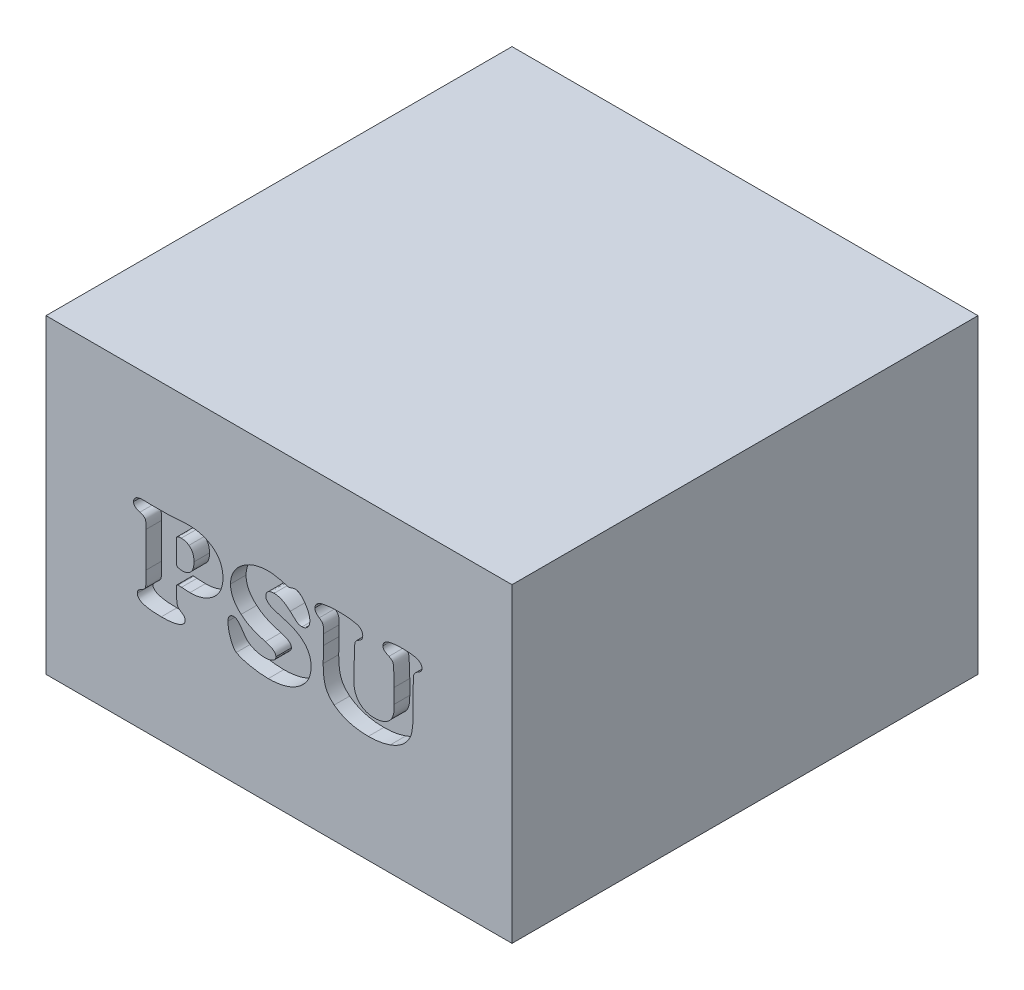
from build123d import *

# Parameters (mm, degrees)
SKETCH1_W           = 150
SKETCH1_H           = 100
BOSS_EXTRUDE1_DEPTH = 150
CUT_EXTRUDE1_DEPTH  = 5


with BuildPart() as part:
    # Sketch1 → Boss-Extrude1 (new body)
    with BuildSketch(Plane.XY):
        Rectangle(SKETCH1_W, SKETCH1_H)
    extrude(amount=BOSS_EXTRUDE1_DEPTH)

    # Sketch2 → Cut-Extrude1 (cut)
    with BuildSketch(Plane.XY.offset(150)):
        with BuildLine():
            Line((-42.77027027, -4.80785473), (-42.77027027, 6.549831081))
            add(Edge.make_bspline(
                [(-42.77027027, 6.549831081), (-42.772098153, 6.725076622), (-42.775578205, 7.058721365), (-42.784930055, 7.534192395), (-42.813709706, 7.958319786), (-42.838004289, 8.333692021), (-42.894502709, 8.655443685), (-42.940993941, 8.931795845), (-43.000430271, 9.158369889), (-43.105235457, 9.400980283), (-43.320470361, 9.658958937), (-43.69595349, 9.913608546), (-44.199479498, 10.134999027), (-44.586565073, 10.245828929), (-44.797297297, 10.306165541)],
                knots=[0, 0, 0, 0, 1.304378784, 2.483367747, 3.538098266, 4.46856333, 5.279790937, 5.967099256, 6.554232707, 7.018535437, 7.924119045, 9.005552902, 10.36980105, 12, 12, 12, 12], degree=3))
            add(Edge.make_bspline(
                [(-44.797297297, 10.306165541), (-44.956796659, 10.353603075), (-45.259647968, 10.443675659), (-45.673839465, 10.622008889), (-46.029622976, 10.82234981), (-46.315821176, 11.058757957), (-46.545599556, 11.314691154), (-46.708874532, 11.601120539), (-46.806432649, 11.915211484), (-46.818322314, 12.134042341), (-46.824324324, 12.244510135)],
                knots=[0, 0, 0, 0, 1.316136863, 2.499030521, 3.562546638, 4.536248738, 5.424589138, 6.270403347, 7.126883983, 8, 8, 8, 8], degree=3))
            add(Edge.make_bspline(
                [(-46.824324324, 12.244510135), (-46.815263653, 12.397865405), (-46.79765399, 12.695915569), (-46.640540067, 13.11398885), (-46.375274516, 13.468839318), (-46.006840918, 13.757650898), (-45.544234503, 13.982228937), (-44.992489559, 14.145372005), (-44.352684354, 14.236682599), (-43.898103778, 14.247041637), (-43.657094595, 14.252533784)],
                knots=[0, 0, 0, 0, 0.870962006, 1.6927385, 2.500678786, 3.364391329, 4.332200649, 5.412372546, 6.628093649, 8, 8, 8, 8], degree=3))
            add(Edge.make_bspline(
                [(-43.657094595, 14.252533784), (-43.540968475, 14.250125309), (-43.243281066, 14.243951223), (-42.702475979, 14.243371633), (-41.972284529, 14.208974172), (-41.423178303, 14.196272251), (-41.116976351, 14.189189189)],
                knots=[0, 0, 0, 0, 0.548528131, 1.406142903, 2.553569298, 4, 4, 4, 4], degree=3))
            Line((-41.116976351, 14.189189189), (-39.831081081, 14.189189189))
            add(Edge.make_bspline(
                [(-39.831081081, 14.189189189), (-39.550256398, 14.192078043), (-39.020286032, 14.197529867), (-38.270673852, 14.193493368), (-37.614010856, 14.20081389), (-37.048167068, 14.210427578), (-36.575136487, 14.205767957), (-36.192966792, 14.213891769), (-35.90371225, 14.220070219), (-35.67337697, 14.225445965), (-35.441509504, 14.243880882), (-35.141175479, 14.251183716), (-34.742474879, 14.28141317), (-34.246147127, 14.310755949), (-33.652891543, 14.350001171), (-32.962417266, 14.394020887), (-32.172711066, 14.444548921), (-31.613174393, 14.480555301), (-31.317567568, 14.499577703)],
                knots=[0, 0, 0, 0, 1.581728074, 2.985026098, 4.22188831, 5.280374816, 6.172301526, 6.88594199, 7.433119622, 7.801974425, 8.183272369, 8.742718937, 9.493445995, 10.434821951, 11.543110428, 12.842047549, 14.331633399, 16, 16, 16, 16], degree=3))
            add(Edge.make_bspline(
                [(-31.317567568, 14.499577703), (-30.922869794, 14.526452896), (-30.169875905, 14.577724673), (-29.415242016, 14.589155486), (-29.056165541, 14.594594595)],
                knots=[0, 0, 0, 0, 1.048342567, 2, 2, 2, 2], degree=3))
            add(Edge.make_bspline(
                [(-29.056165541, 14.594594595), (-28.766815243, 14.588665069), (-28.197995098, 14.577008492), (-27.355516892, 14.516438752), (-26.538401285, 14.397424015), (-25.741037708, 14.251795905), (-24.971549978, 14.046393679), (-24.229188453, 13.795642433), (-23.502800478, 13.517183891), (-23.040904426, 13.285144056), (-22.810388514, 13.169341216)],
                knots=[0, 0, 0, 0, 1.073806442, 2.11094559, 3.131408765, 4.136324753, 5.116910564, 6.083150564, 7.043368532, 8, 8, 8, 8], degree=3))
            add(Edge.make_bspline(
                [(-22.810388514, 13.169341216), (-22.432447417, 12.959633997), (-21.696163971, 12.551094265), (-20.721601009, 11.786626748), (-19.88693541, 10.941345718), (-19.204518995, 9.998496719), (-18.682947262, 8.959506883), (-18.307220781, 7.833788986), (-18.082683203, 6.617834481), (-18.054848456, 5.777989792), (-18.040540541, 5.346283784)],
                knots=[0, 0, 0, 0, 1.068766056, 2.082109524, 3.054420253, 4.001901685, 4.951155553, 5.921609222, 6.931643197, 8, 8, 8, 8], degree=3))
            add(Edge.make_bspline(
                [(-18.040540541, 5.346283784), (-18.049754855, 4.993085393), (-18.067776802, 4.302277277), (-18.22429312, 3.293333749), (-18.476859743, 2.336827925), (-18.832478108, 1.432473224), (-19.29138141, 0.583260635), (-19.856154976, -0.206920047), (-20.516675217, -0.949396449), (-21.02506347, -1.386506222), (-21.283783784, -1.608952703)],
                knots=[0, 0, 0, 0, 1.065407665, 2.0837928, 3.073052064, 4.045753518, 5.009500808, 5.978437762, 6.971220887, 8, 8, 8, 8], degree=3))
            add(Edge.make_bspline(
                [(-21.283783784, -1.608952703), (-21.54253317, -1.803399498), (-22.058179146, -2.190900736), (-22.88388564, -2.691639244), (-23.75154583, -3.113017398), (-24.66079063, -3.452179365), (-25.605823372, -3.729229279), (-26.594556314, -3.915858733), (-27.621725019, -4.033165494), (-28.321042624, -4.047019925), (-28.676097973, -4.054054054)],
                knots=[0, 0, 0, 0, 0.97791957, 1.948836665, 2.913671988, 3.889276902, 4.879079586, 5.886727176, 6.927055728, 8, 8, 8, 8], degree=3))
            add(Edge.make_bspline(
                [(-28.676097973, -4.054054054), (-28.870405211, -4.05370254), (-29.280385971, -4.05296086), (-29.924193976, -4.014821322), (-30.631912283, -3.973499523), (-31.123399671, -3.930756494), (-31.380912162, -3.908361486)],
                knots=[0, 0, 0, 0, 0.860351216, 1.815307805, 2.855340867, 4, 4, 4, 4], degree=3))
            add(Edge.make_bspline(
                [(-31.380912162, -3.908361486), (-31.509802045, -3.901304), (-31.740246919, -3.888685775), (-32.043387073, -3.85444424), (-32.26782293, -3.853470886), (-32.390216001, -3.847417965), (-32.438766892, -3.845016892)],
                knots=[0, 0, 0, 0, 1.461298414, 2.612685507, 3.449679997, 4, 4, 4, 4], degree=3))
            add(Edge.make_bspline(
                [(-32.438766892, -3.845016892), (-32.530199644, -3.850692056), (-32.698518331, -3.861139473), (-32.909349355, -4.015883792), (-33.026651189, -4.261075027), (-33.035575192, -4.449587383), (-33.040540541, -4.554476351)],
                knots=[0, 0, 0, 0, 1.019207184, 1.876260002, 2.818343254, 4, 4, 4, 4], degree=3))
            Line((-33.040540541, -4.554476351), (-33.040540541, -4.6875))
            Line((-33.040540541, -4.6875), (-32.913851351, -8.266469595))
            add(Edge.make_bspline(
                [(-32.913851351, -8.266469595), (-32.906986676, -8.43150715), (-32.894158717, -8.739911371), (-32.822198275, -9.165730641), (-32.730321054, -9.526029207), (-32.603697549, -9.836683521), (-32.39947337, -10.104367541), (-32.139911777, -10.367739962), (-31.803761796, -10.637247572), (-31.545353563, -10.800861114), (-31.40625, -10.888935811)],
                knots=[0, 0, 0, 0, 1.233123819, 2.304327576, 3.218979559, 4.010344749, 4.789825713, 5.715836909, 6.770413693, 8, 8, 8, 8], degree=3))
            add(Edge.make_bspline(
                [(-31.40625, -10.888935811), (-31.225943003, -11.011459938), (-30.892072713, -11.238335028), (-30.498466323, -11.645273868), (-30.251050891, -12.087513351), (-30.218480359, -12.398107638), (-30.202702703, -12.548564189)],
                knots=[0, 0, 0, 0, 1.221363424, 2.261570366, 3.157878497, 4, 4, 4, 4], degree=3))
            add(Edge.make_bspline(
                [(-30.202702703, -12.548564189), (-30.208339248, -12.661242763), (-30.219401552, -12.882386127), (-30.321936655, -13.202780425), (-30.480954465, -13.500676146), (-30.702672362, -13.781216895), (-30.992694702, -14.03067268), (-31.339553099, -14.269492583), (-31.752839247, -14.479227162), (-32.22180073, -14.677279156), (-32.749231333, -14.843320305), (-33.327426976, -14.998326001), (-33.961096869, -15.120150045), (-34.645147967, -15.229677186), (-35.380869346, -15.310209606), (-36.168979371, -15.367020876), (-37.009904976, -15.396828437), (-37.588662035, -15.402491868), (-37.886402027, -15.405405405)],
                knots=[0, 0, 0, 0, 0.608555612, 1.194353375, 1.802908987, 2.429555441, 3.117818332, 3.86611836, 4.704673923, 5.621827583, 6.619575506, 7.695405557, 8.861186678, 10.110981752, 11.4453282, 12.866553572, 14.38800702, 16, 16, 16, 16], degree=3))
            add(Edge.make_bspline(
                [(-37.886402027, -15.405405405), (-38.198936039, -15.402728914), (-38.803051494, -15.397555366), (-39.677417187, -15.364957798), (-40.491154713, -15.317779851), (-41.245018342, -15.239656032), (-41.94123626, -15.149007352), (-42.575165081, -15.028091486), (-43.148194132, -14.888902474), (-43.664458934, -14.733669744), (-44.119547769, -14.550210105), (-44.518241589, -14.350664987), (-44.850253434, -14.119530893), (-45.127504287, -13.874241819), (-45.342554353, -13.602044319), (-45.497282108, -13.308521865), (-45.58897188, -12.991005111), (-45.601676877, -12.772958828), (-45.608108108, -12.662584459)],
                knots=[0, 0, 0, 0, 1.689926572, 3.266558902, 4.730835148, 6.09639393, 7.363928849, 8.526092547, 9.583911449, 10.551765952, 11.437992987, 12.234595649, 12.956694184, 13.619492535, 14.229334567, 14.82171949, 15.403557975, 16, 16, 16, 16], degree=3))
            add(Edge.make_bspline(
                [(-45.608108108, -12.662584459), (-45.605552284, -12.560816261), (-45.600702077, -12.367689929), (-45.535312802, -12.097648728), (-45.434724908, -11.864143045), (-45.28131565, -11.653945318), (-45.041713241, -11.458867394), (-44.720738416, -11.224710797), (-44.285037044, -10.962347151), (-43.95752389, -10.780101607), (-43.777449324, -10.679898649)],
                knots=[0, 0, 0, 0, 0.847917435, 1.609099773, 2.303662714, 2.95955692, 3.758981144, 4.869845424, 6.27896615, 8, 8, 8, 8], degree=3))
            add(Edge.make_bspline(
                [(-43.777449324, -10.679898649), (-43.6635859, -10.608931856), (-43.446536201, -10.473652937), (-43.194198242, -10.195647227), (-43.005181015, -9.886140621), (-42.930574528, -9.574743119), (-42.890772095, -9.266149308), (-42.867598886, -8.929740775), (-42.852766713, -8.490210756), (-42.823183015, -7.949985113), (-42.806269356, -7.307935457), (-42.795108611, -6.564621276), (-42.782138818, -5.720027721), (-42.774363793, -5.122467873), (-42.77027027, -4.80785473)],
                knots=[0, 0, 0, 0, 0.774534769, 1.47644021, 2.156973803, 2.855130009, 3.312368001, 3.963276809, 4.809081543, 5.863416552, 7.100855535, 8.533901848, 10.175111598, 12, 12, 12, 12], degree=3))
        make_face()
        with BuildLine():
            Line((-33.040540541, 8.937922297), (-33.040540541, 2.046030405))
            add(Edge.make_bspline(
                [(-33.040540541, 2.046030405), (-33.035279184, 1.927430114), (-33.025789257, 1.71351037), (-32.97085559, 1.428583163), (-32.857545514, 1.209710002), (-32.736157434, 1.132100536), (-32.679476351, 1.095861486)],
                knots=[0, 0, 0, 0, 1.332666798, 2.403735578, 3.254638544, 4, 4, 4, 4], degree=3))
            add(Edge.make_bspline(
                [(-32.679476351, 1.095861486), (-32.570738213, 1.050444647), (-32.343650185, 0.955596411), (-31.969138667, 0.872987208), (-31.557629792, 0.821690172), (-31.271298524, 0.814552491), (-31.121199324, 0.810810811)],
                knots=[0, 0, 0, 0, 0.884646688, 1.847490436, 2.871621796, 4, 4, 4, 4], degree=3))
            add(Edge.make_bspline(
                [(-31.121199324, 0.810810811), (-30.894163994, 0.817158238), (-30.453995361, 0.829464421), (-29.828790774, 0.986462606), (-29.24731477, 1.205247624), (-28.916839528, 1.440842745), (-28.752111486, 1.558277027)],
                knots=[0, 0, 0, 0, 1.074135802, 2.082499173, 3.044206298, 4, 4, 4, 4], degree=3))
            add(Edge.make_bspline(
                [(-28.752111486, 1.558277027), (-28.641838801, 1.652657732), (-28.419934209, 1.842582477), (-28.131128861, 2.1811593), (-27.899137253, 2.574535959), (-27.702227398, 3.005080905), (-27.548224489, 3.481031306), (-27.445302412, 4.004140495), (-27.37137836, 4.571392545), (-27.367077318, 4.965955868), (-27.364864865, 5.168918919)],
                knots=[0, 0, 0, 0, 0.868631122, 1.747968979, 2.650290547, 3.595469487, 4.579371631, 5.638514062, 6.78525356, 8, 8, 8, 8], degree=3))
            add(Edge.make_bspline(
                [(-27.364864865, 5.168918919), (-27.369518037, 5.380293185), (-27.378577164, 5.791811705), (-27.454412461, 6.386085864), (-27.580682107, 6.93611867), (-27.755927171, 7.4394412), (-27.988569421, 7.89575871), (-28.265697671, 8.309451791), (-28.598662852, 8.677243282), (-28.856687438, 8.880177585), (-28.986486486, 8.982263514)],
                knots=[0, 0, 0, 0, 1.176877362, 2.291228906, 3.329522002, 4.3151368, 5.251244687, 6.174261593, 7.081563852, 8, 8, 8, 8], degree=3))
            add(Edge.make_bspline(
                [(-28.986486486, 8.982263514), (-29.162245901, 9.099009353), (-29.516190811, 9.334112522), (-30.122923476, 9.562972596), (-30.776400303, 9.708020219), (-31.230164063, 9.722362285), (-31.463260135, 9.72972973)],
                knots=[0, 0, 0, 0, 0.959890449, 1.933030663, 2.938208655, 4, 4, 4, 4], degree=3))
            add(Edge.make_bspline(
                [(-31.463260135, 9.72972973), (-31.585797557, 9.727494269), (-31.816762059, 9.723280764), (-32.139876968, 9.687634644), (-32.413071286, 9.623562212), (-32.642716745, 9.546850732), (-32.817073307, 9.430703792), (-32.947178837, 9.29146077), (-33.026553247, 9.122653436), (-33.035843941, 8.999950601), (-33.040540541, 8.937922297)],
                knots=[0, 0, 0, 0, 1.499842154, 2.826975554, 3.967922457, 4.932841553, 5.771477936, 6.503369428, 7.243428591, 8, 8, 8, 8], degree=3))
        make_face(mode=Mode.SUBTRACT)
        with BuildLine():
            add(Edge.make_bspline(
                [(-3.325591216, 14.594594595), (-3.13334966, 14.590193431), (-2.731398388, 14.580991188), (-2.108022288, 14.527227583), (-1.439732874, 14.44625339), (-0.730780236, 14.321817358), (0.022393111, 14.172849333), (0.817001186, 13.977309078), (1.656325253, 13.758874276), (2.228047777, 13.591079693), (2.521114865, 13.505067568)],
                knots=[0, 0, 0, 0, 0.773334932, 1.61693947, 2.515573817, 3.480445069, 4.511531103, 5.603376372, 6.771481835, 8, 8, 8, 8], degree=3))
            add(Edge.make_bspline(
                [(2.521114865, 13.505067568), (2.65115828, 13.468351964), (2.879586781, 13.403858962), (3.116056804, 13.386049141), (3.217905405, 13.378378378)],
                knots=[0, 0, 0, 0, 1.138591857, 2, 2, 2, 2], degree=3))
            add(Edge.make_bspline(
                [(3.217905405, 13.378378378), (3.273008872, 13.38579488), (3.419057909, 13.405451955), (3.688728389, 13.484131726), (4.065903638, 13.604311409), (4.35406844, 13.70288998), (4.516469595, 13.758445946)],
                knots=[0, 0, 0, 0, 0.491859576, 1.303649695, 2.48041676, 4, 4, 4, 4], degree=3))
            add(Edge.make_bspline(
                [(4.516469595, 13.758445946), (4.635773098, 13.79803628), (4.874397123, 13.877222595), (5.125637663, 13.886720369), (5.251266892, 13.891469595)],
                knots=[0, 0, 0, 0, 0.999928683, 2, 2, 2, 2], degree=3))
            add(Edge.make_bspline(
                [(5.251266892, 13.891469595), (5.374314316, 13.882908918), (5.624327714, 13.865514944), (6.000988583, 13.759604475), (6.376429249, 13.573863962), (6.764962752, 13.330308217), (7.141758409, 12.995461336), (7.539278788, 12.610089079), (7.935029606, 12.146013541), (8.324001451, 11.622541657), (8.696558564, 11.072480681), (9.029523488, 10.516474351), (9.298722854, 9.962324648), (9.533133348, 9.421783022), (9.710070402, 8.883002262), (9.836739112, 8.351219681), (9.917809962, 7.8255445), (9.927573582, 7.477056332), (9.932432432, 7.303631757)],
                knots=[0, 0, 0, 0, 0.684457719, 1.390712585, 2.157308825, 3.007185041, 3.93153842, 4.952505252, 6.084389297, 7.316916367, 8.576863306, 9.776704447, 10.915869125, 11.999427841, 13.049928463, 14.063513329, 15.036310526, 16, 16, 16, 16], degree=3))
            add(Edge.make_bspline(
                [(9.932432432, 7.303631757), (9.92524492, 7.110480321), (9.911295361, 6.735611048), (9.76418803, 6.199539576), (9.534919633, 5.707293215), (9.211866202, 5.277081669), (8.832399056, 4.91283601), (8.395407112, 4.655741855), (7.922094089, 4.484188471), (7.588086595, 4.467814588), (7.417652027, 4.459459459)],
                knots=[0, 0, 0, 0, 1.096137936, 2.127389986, 3.137372452, 4.167854936, 5.17052742, 6.107691631, 7.034408616, 8, 8, 8, 8], degree=3))
            add(Edge.make_bspline(
                [(7.417652027, 4.459459459), (7.277876329, 4.461370934), (7.011127625, 4.465018803), (6.633200427, 4.539935887), (6.292139019, 4.644048605), (6.029940115, 4.778262546), (5.817359829, 4.924869707), (5.620907786, 5.079907748), (5.383037358, 5.275059032), (5.100381878, 5.50925125), (4.787961295, 5.797416044), (4.426270587, 6.1197395), (4.017579051, 6.479096179), (3.738657537, 6.741113906), (3.591638514, 6.879222973)],
                knots=[0, 0, 0, 0, 1.077980461, 2.057223784, 2.965377725, 3.82643366, 4.319711792, 4.959381373, 5.759540393, 6.697543975, 7.795103434, 9.043052033, 10.441398099, 12, 12, 12, 12], degree=3))
            add(Edge.make_bspline(
                [(3.591638514, 6.879222973), (3.376460889, 7.071909279), (2.957075725, 7.447458448), (2.306914399, 7.951239581), (1.650982096, 8.365408683), (1.010032552, 8.725308998), (0.361698658, 8.989034529), (-0.282624388, 9.182407399), (-0.924642037, 9.301554478), (-1.352986455, 9.316794794), (-1.564611486, 9.324324324)],
                knots=[0, 0, 0, 0, 1.18634838, 2.312214905, 3.373239167, 4.370712315, 5.327458093, 6.241293552, 7.131105035, 8, 8, 8, 8], degree=3))
            add(Edge.make_bspline(
                [(-1.564611486, 9.324324324), (-1.759189262, 9.316373508), (-2.130091059, 9.301217758), (-2.661707286, 9.204870325), (-3.12615599, 9.016591504), (-3.5326218, 8.774253518), (-3.850757652, 8.460042849), (-4.089208134, 8.101844913), (-4.234941009, 7.692253494), (-4.249357992, 7.401942874), (-4.256756757, 7.252956081)],
                knots=[0, 0, 0, 0, 1.22680445, 2.338519772, 3.383741579, 4.369685134, 5.301239555, 6.175937312, 7.06389491, 8, 8, 8, 8], degree=3))
            add(Edge.make_bspline(
                [(-4.256756757, 7.252956081), (-4.247672915, 7.103645966), (-4.229489689, 6.804770286), (-4.059060109, 6.377674844), (-3.792612591, 5.983446723), (-3.416961684, 5.625019635), (-2.945613381, 5.290686525), (-2.36901893, 4.989148224), (-1.691193298, 4.716823647), (-1.198609566, 4.569320473), (-0.9375, 4.491131757)],
                knots=[0, 0, 0, 0, 0.771184117, 1.543687626, 2.348175458, 3.222801976, 4.219098112, 5.33555604, 6.587627318, 8, 8, 8, 8], degree=3))
            add(Edge.make_bspline(
                [(-0.9375, 4.491131757), (-0.580390841, 4.38857699), (0.100960388, 4.192906244), (1.068948709, 3.899570127), (1.939986356, 3.634912947), (2.708315047, 3.388952367), (3.378180758, 3.166536631), (3.945812381, 2.968023683), (4.411466137, 2.783021868), (4.685651577, 2.663200925), (4.80785473, 2.609797297)],
                knots=[0, 0, 0, 0, 1.473999505, 2.812337199, 4.012690354, 5.085619275, 6.012771145, 6.812928632, 7.470927909, 8, 8, 8, 8], degree=3))
            add(Edge.make_bspline(
                [(4.80785473, 2.609797297), (5.033229818, 2.500846462), (5.475850159, 2.286874916), (6.099829894, 1.922128769), (6.685864253, 1.549886472), (7.227906408, 1.15724512), (7.722041427, 0.736492546), (8.177097497, 0.301068132), (8.594562141, -0.150094783), (8.960936755, -0.626397129), (9.286334242, -1.121290769), (9.564090174, -1.637939079), (9.807609473, -2.166893159), (9.997902581, -2.721622631), (10.149952311, -3.293022742), (10.254889887, -3.886525703), (10.330812681, -4.495507733), (10.335476912, -4.908962177), (10.337837838, -5.118243243)],
                knots=[0, 0, 0, 0, 1.190175304, 2.337418046, 3.435015623, 4.491600174, 5.517725277, 6.519228743, 7.485938742, 8.438089578, 9.374001488, 10.299728363, 11.225618644, 12.140330766, 13.085464763, 14.034910694, 15.005317296, 16, 16, 16, 16], degree=3))
            add(Edge.make_bspline(
                [(10.337837838, -5.118243243), (10.327870967, -5.486405246), (10.308274027, -6.210288215), (10.124463615, -7.26678495), (9.832692247, -8.273393774), (9.420096035, -9.228373307), (8.880890931, -10.127549842), (8.228757959, -10.973462435), (7.46550118, -11.77467326), (6.880786726, -12.244659397), (6.581503378, -12.485219595)],
                knots=[0, 0, 0, 0, 1.027652808, 2.020578873, 2.985519544, 3.9497389, 4.917775107, 5.90636473, 6.928382616, 8, 8, 8, 8], degree=3))
            add(Edge.make_bspline(
                [(6.581503378, -12.485219595), (6.252101388, -12.719768952), (5.589857492, -13.191317043), (4.512099123, -13.784528765), (3.362833718, -14.288168654), (2.139569073, -14.698736787), (0.841934524, -15.013466206), (-0.52573537, -15.239544091), (-1.966943676, -15.383233227), (-2.953619583, -15.397899163), (-3.458614865, -15.405405405)],
                knots=[0, 0, 0, 0, 0.911251608, 1.832019331, 2.767976302, 3.737636716, 4.737705264, 5.77565062, 6.861545178, 8, 8, 8, 8], degree=3))
            add(Edge.make_bspline(
                [(-3.458614865, -15.405405405), (-3.925487851, -15.398188814), (-4.875513166, -15.383503998), (-6.317764181, -15.25800496), (-7.796733867, -15.052454503), (-9.039341847, -14.824857231), (-10.017050324, -14.608380539), (-10.703206293, -14.436257628), (-11.338743173, -14.262362874), (-11.917537905, -14.069712935), (-12.449154051, -13.883848611), (-12.91995466, -13.67879488), (-13.345635598, -13.480492024), (-13.599182491, -13.325711629), (-13.720439189, -13.251689189)],
                knots=[0, 0, 0, 0, 1.588377764, 3.232140496, 4.921862013, 6.667833788, 7.528935282, 8.328750665, 9.074841091, 9.770077056, 10.40415461, 10.989995517, 11.516973737, 12, 12, 12, 12], degree=3))
            add(Edge.make_bspline(
                [(-13.720439189, -13.251689189), (-13.806112907, -13.187770331), (-13.985190556, -13.054165311), (-14.241580575, -12.812559644), (-14.477834508, -12.510818175), (-14.713233288, -12.165055082), (-14.949398489, -11.774380876), (-15.165002218, -11.327040828), (-15.393147805, -10.839194656), (-15.661576475, -10.119410869), (-15.963288411, -9.195844352), (-16.221183666, -8.078918447), (-16.390678093, -6.977323598), (-16.40957102, -6.246374186), (-16.418918919, -5.884712838)],
                knots=[0, 0, 0, 0, 0.47725386, 0.997569625, 1.567562592, 2.184896417, 2.865804552, 3.603874814, 4.401537228, 5.270238753, 7.032874617, 8.737122659, 10.385583738, 12, 12, 12, 12], degree=3))
            add(Edge.make_bspline(
                [(-16.418918919, -5.884712838), (-16.415516208, -5.721614986), (-16.40914485, -5.416224768), (-16.324583504, -4.989278369), (-16.192940264, -4.621051082), (-16.049663461, -4.421090283), (-15.981841216, -4.326435811)],
                knots=[0, 0, 0, 0, 1.184443567, 2.217794261, 3.156365926, 4, 4, 4, 4], degree=3))
            add(Edge.make_bspline(
                [(-15.981841216, -4.326435811), (-15.889171341, -4.222215225), (-15.710904434, -4.021728481), (-15.374386894, -3.807208021), (-15.003499113, -3.673329996), (-14.741445301, -3.657006775), (-14.607263514, -3.648648649)],
                knots=[0, 0, 0, 0, 1.050954595, 2.021697176, 2.987031679, 4, 4, 4, 4], degree=3))
            add(Edge.make_bspline(
                [(-14.607263514, -3.648648649), (-14.468714941, -3.65883357), (-14.185563985, -3.679648438), (-13.77053656, -3.842733238), (-13.37375574, -4.110984338), (-13.13617707, -4.343345867), (-13.01097973, -4.465793919)],
                knots=[0, 0, 0, 0, 0.900274855, 1.839886768, 2.86168051, 4, 4, 4, 4], degree=3))
            add(Edge.make_bspline(
                [(-13.01097973, -4.465793919), (-12.966367713, -4.514110017), (-12.859763806, -4.629565117), (-12.683536206, -4.836452894), (-12.476804504, -5.1140625), (-12.220031743, -5.447813047), (-11.934333085, -5.853210225), (-11.600136815, -6.316447722), (-11.237505563, -6.847682212), (-10.979885252, -7.221394867), (-10.844594595, -7.417652027)],
                knots=[0, 0, 0, 0, 0.430740811, 1.029288892, 1.778934584, 2.69726761, 3.787316251, 5.026880487, 6.438650696, 8, 8, 8, 8], degree=3))
            add(Edge.make_bspline(
                [(-10.844594595, -7.417652027), (-10.697006207, -7.611650991), (-10.3930987, -8.01112511), (-9.790193455, -8.512747531), (-9.088189159, -8.98150918), (-8.276184431, -9.37908028), (-7.400944541, -9.712931041), (-6.494090467, -9.951830768), (-5.573172737, -10.105268983), (-4.9541438, -10.125148268), (-4.643158784, -10.135135135)],
                knots=[0, 0, 0, 0, 0.8332964, 1.715887239, 2.671600917, 3.723780634, 4.807464992, 5.87859998, 6.934260452, 8, 8, 8, 8], degree=3))
            add(Edge.make_bspline(
                [(-4.643158784, -10.135135135), (-4.385262495, -10.127238368), (-3.892673479, -10.112155326), (-3.191546383, -10.015714146), (-2.568339513, -9.838360204), (-2.030452005, -9.592944291), (-1.580517889, -9.299621491), (-1.261101492, -8.941453781), (-1.047627866, -8.545104116), (-1.024922021, -8.258464227), (-1.013513514, -8.114442568)],
                knots=[0, 0, 0, 0, 1.355034506, 2.588153232, 3.708150479, 4.745608851, 5.687179247, 6.504336872, 7.248506944, 8, 8, 8, 8], degree=3))
            add(Edge.make_bspline(
                [(-1.013513514, -8.114442568), (-1.023629828, -7.98009637), (-1.04383357, -7.711787608), (-1.198303339, -7.326700925), (-1.454578802, -6.976784269), (-1.819642221, -6.664288287), (-2.285339011, -6.363122316), (-2.874712029, -6.083089316), (-3.58507189, -5.812819003), (-4.105654141, -5.657307816), (-4.383445946, -5.574324324)],
                knots=[0, 0, 0, 0, 0.712810623, 1.423585779, 2.171246847, 2.998045855, 3.963141611, 5.112689572, 6.459280596, 8, 8, 8, 8], degree=3))
            add(Edge.make_bspline(
                [(-4.383445946, -5.574324324), (-4.874243901, -5.42954776), (-5.798636664, -5.156868531), (-7.084084441, -4.728277286), (-8.182888027, -4.3143629), (-9.119298552, -3.900198933), (-9.944093357, -3.459409583), (-10.720317149, -2.98424742), (-11.466889064, -2.451631255), (-11.942516223, -2.063442177), (-12.181165541, -1.868665541)],
                knots=[0, 0, 0, 0, 1.4100512, 2.655759074, 3.733164465, 4.644773426, 5.475138884, 6.308434908, 7.151245159, 8, 8, 8, 8], degree=3))
            add(Edge.make_bspline(
                [(-12.181165541, -1.868665541), (-12.454490653, -1.622613627), (-12.988135236, -1.1422177), (-13.682538001, -0.352016491), (-14.279712764, 0.454513637), (-14.764562247, 1.289103113), (-15.144811582, 2.150979965), (-15.406401984, 3.041459903), (-15.583193388, 3.954169907), (-15.599767829, 4.572648875), (-15.608108108, 4.883868243)],
                knots=[0, 0, 0, 0, 1.127646448, 2.201636043, 3.221533347, 4.202810364, 5.157392316, 6.104424208, 7.046143958, 8, 8, 8, 8], degree=3))
            add(Edge.make_bspline(
                [(-15.608108108, 4.883868243), (-15.596750415, 5.19497146), (-15.574108048, 5.815177764), (-15.40231469, 6.73856847), (-15.121262479, 7.647093258), (-14.733850389, 8.538640531), (-14.250465688, 9.397900106), (-13.662642592, 10.200360252), (-12.981645332, 10.941426172), (-12.466877956, 11.377715625), (-12.206503378, 11.59839527)],
                knots=[0, 0, 0, 0, 0.959069708, 1.911973412, 2.886287422, 3.886736069, 4.904478038, 5.920447572, 6.948141217, 8, 8, 8, 8], degree=3))
            add(Edge.make_bspline(
                [(-12.206503378, 11.59839527), (-11.900706845, 11.839224495), (-11.290821923, 12.319537697), (-10.296821525, 12.922646176), (-9.256829606, 13.440691968), (-8.168133395, 13.86641903), (-7.025602353, 14.18818274), (-5.83722154, 14.420601674), (-4.598577802, 14.573704124), (-3.754686565, 14.587552883), (-3.325591216, 14.594594595)],
                knots=[0, 0, 0, 0, 0.975770284, 1.94609002, 2.910288353, 3.888112696, 4.874067793, 5.883869659, 6.924006262, 8, 8, 8, 8], degree=3))
        make_face()
        with BuildLine():
            Line((43.175675676, 3.547297297), (43.175675676, -1.640625))
            add(Edge.make_bspline(
                [(43.175675676, -1.640625), (43.172775662, -2.016484956), (43.167186369, -2.740892353), (43.137830575, -3.786553485), (43.080358623, -4.747530473), (43.005525594, -5.62213442), (42.913239286, -6.411009404), (42.794908897, -7.113389297), (42.652187278, -7.731847569), (42.529874539, -8.108805487), (42.472550676, -8.285472973)],
                knots=[0, 0, 0, 0, 1.344732378, 2.591747444, 3.741996797, 4.78841022, 5.73195967, 6.582671205, 7.335745707, 8, 8, 8, 8], degree=3))
            add(Edge.make_bspline(
                [(42.472550676, -8.285472973), (42.335385616, -8.621089233), (42.06228528, -9.28931271), (41.500181885, -10.218825446), (40.833079761, -11.07824351), (40.048874499, -11.865562396), (39.153494551, -12.580032249), (38.14356259, -13.224360237), (37.017032139, -13.786370861), (36.214702914, -14.098471521), (35.802364865, -14.258868243)],
                knots=[0, 0, 0, 0, 0.93871332, 1.869010392, 2.805166776, 3.753454596, 4.742524668, 5.768981711, 6.853421138, 8, 8, 8, 8], degree=3))
            add(Edge.make_bspline(
                [(35.802364865, -14.258868243), (35.26902123, -14.436370199), (34.18238544, -14.798013171), (32.459496229, -15.148309657), (30.639308806, -15.369425294), (29.390466953, -15.393234923), (28.752111486, -15.405405405)],
                knots=[0, 0, 0, 0, 0.938973649, 1.913067499, 2.933247819, 4, 4, 4, 4], degree=3))
            add(Edge.make_bspline(
                [(28.752111486, -15.405405405), (28.194310945, -15.396216971), (27.10610521, -15.378291374), (25.51646127, -15.223018843), (24.010529726, -14.9727032), (22.588657433, -14.618811416), (21.250022436, -14.166042555), (20.005473658, -13.595139927), (18.833778332, -12.942233137), (18.122004349, -12.416958494), (17.768158784, -12.155827703)],
                knots=[0, 0, 0, 0, 1.146887801, 2.237448317, 3.281122936, 4.283728673, 5.247714551, 6.182434806, 7.096430328, 8, 8, 8, 8], degree=3))
            add(Edge.make_bspline(
                [(17.768158784, -12.155827703), (17.452226354, -11.887211875), (16.835987431, -11.363265891), (16.058301798, -10.458723467), (15.428365216, -9.496489081), (15.031850706, -8.629714132), (14.801896319, -7.886308785), (14.640350944, -7.274376925), (14.509653446, -6.601307783), (14.404015156, -5.869746851), (14.321142485, -5.079446359), (14.267974204, -4.231957653), (14.227019405, -3.325982971), (14.222954923, -2.70275446), (14.220861486, -2.381756757)],
                knots=[0, 0, 0, 0, 1.376233547, 2.684398938, 3.947382072, 5.187652958, 5.835563631, 6.531566699, 7.289720259, 8.112273296, 8.987029239, 9.929295608, 10.93347088, 12, 12, 12, 12], degree=3))
            add(Edge.make_bspline(
                [(14.220861486, -2.381756757), (14.220375602, -2.242395263), (14.219330164, -1.942543007), (14.228486682, -1.461161722), (14.23241428, -0.916337588), (14.245745328, -0.310319332), (14.266507748, 0.358915944), (14.285112438, 1.089504792), (14.302483794, 1.883521682), (14.319639093, 2.432444711), (14.328547297, 2.717483108)],
                knots=[0, 0, 0, 0, 0.65572948, 1.410877273, 2.265370417, 3.219365715, 4.262997418, 5.415877012, 6.658146525, 8, 8, 8, 8], degree=3))
            add(Edge.make_bspline(
                [(14.328547297, 2.717483108), (14.33266426, 2.918076774), (14.340508339, 3.300269355), (14.353385106, 3.84713935), (14.365551632, 4.34124643), (14.379401175, 4.782452873), (14.387778019, 5.170996337), (14.382458033, 5.504702741), (14.393607722, 5.785429802), (14.392424339, 5.95438594), (14.391891892, 6.030405405)],
                knots=[0, 0, 0, 0, 1.45314883, 2.768695108, 3.961934527, 5.032875417, 5.965868566, 6.776393052, 7.449455066, 8, 8, 8, 8], degree=3))
            add(Edge.make_bspline(
                [(14.391891892, 6.030405405), (14.387147906, 6.30275278), (14.378461642, 6.80142239), (14.344675961, 7.484470612), (14.255566875, 8.028439441), (14.14548154, 8.466798351), (13.959826562, 8.828283834), (13.699172985, 9.151426863), (13.363861817, 9.466224081), (13.100221854, 9.650784202), (12.960304054, 9.748733108)],
                knots=[0, 0, 0, 0, 1.548976585, 2.836185047, 3.88214687, 4.680231356, 5.394261667, 6.172323433, 7.030023822, 8, 8, 8, 8], degree=3))
            add(Edge.make_bspline(
                [(12.960304054, 9.748733108), (12.747964776, 9.896466727), (12.353071338, 10.171211172), (11.907614082, 10.681759553), (11.606420651, 11.218377711), (11.571248692, 11.601251981), (11.554054054, 11.788429054)],
                knots=[0, 0, 0, 0, 1.198633105, 2.229132328, 3.134269778, 4, 4, 4, 4], degree=3))
            add(Edge.make_bspline(
                [(11.554054054, 11.788429054), (11.56244997, 11.924716916), (11.578970032, 12.19288107), (11.716169524, 12.578383652), (11.927699504, 12.940532005), (12.232141035, 13.265719438), (12.593900071, 13.562903096), (13.022765425, 13.80297285), (13.497336775, 14.003969842), (13.841316645, 14.084462718), (14.018158784, 14.125844595)],
                knots=[0, 0, 0, 0, 0.88863173, 1.748498904, 2.645665108, 3.613124913, 4.643520691, 5.694692113, 6.814827228, 8, 8, 8, 8], degree=3))
            add(Edge.make_bspline(
                [(14.018158784, 14.125844595), (14.4039071, 14.197413961), (15.205854803, 14.346202399), (16.470343124, 14.497395452), (17.836866873, 14.573777994), (18.781586249, 14.58750577), (19.269425676, 14.594594595)],
                knots=[0, 0, 0, 0, 0.891374996, 1.853115361, 2.891379812, 4, 4, 4, 4], degree=3))
            add(Edge.make_bspline(
                [(19.269425676, 14.594594595), (19.801725657, 14.58972168), (20.818826506, 14.580410679), (22.273566075, 14.477812856), (23.588972157, 14.316058859), (24.409760385, 14.1398271), (24.799408784, 14.056165541)],
                knots=[0, 0, 0, 0, 1.146950716, 2.191554737, 3.141486467, 4, 4, 4, 4], degree=3))
            add(Edge.make_bspline(
                [(24.799408784, 14.056165541), (24.969772481, 14.012186976), (25.294124702, 13.928457019), (25.738394113, 13.73615502), (26.112444136, 13.501529471), (26.430969858, 13.233803243), (26.663309747, 12.910123682), (26.841747475, 12.554777452), (26.944491352, 12.153019632), (26.954343141, 11.871358971), (26.959459459, 11.725084459)],
                knots=[0, 0, 0, 0, 1.213892521, 2.311107006, 3.326690945, 4.256803329, 5.163880673, 6.057375596, 6.991139073, 8, 8, 8, 8], degree=3))
            add(Edge.make_bspline(
                [(26.959459459, 11.725084459), (26.951516352, 11.583082294), (26.936240786, 11.309994768), (26.836910151, 10.918040007), (26.648700738, 10.575549298), (26.475754229, 10.387458255), (26.389358108, 10.293496622)],
                knots=[0, 0, 0, 0, 1.07591295, 2.069112137, 3.035417245, 4, 4, 4, 4], degree=3))
            add(Edge.make_bspline(
                [(26.389358108, 10.293496622), (26.349475757, 10.26360753), (26.238820348, 10.180678879), (26.016274217, 10.036253568), (25.68370131, 9.849138636), (25.426684539, 9.708302682), (25.280827703, 9.628378378)],
                knots=[0, 0, 0, 0, 0.462112091, 1.282151132, 2.457622691, 4, 4, 4, 4], degree=3))
            add(Edge.make_bspline(
                [(25.280827703, 9.628378378), (25.186653195, 9.571475769), (24.998672494, 9.457893095), (24.771889097, 9.203796064), (24.59409464, 8.892841761), (24.456778582, 8.509728806), (24.378785165, 8.032024573), (24.305272741, 7.442959672), (24.274496393, 6.725355418), (24.269827002, 6.203535068), (24.267314189, 5.922719595)],
                knots=[0, 0, 0, 0, 0.653481225, 1.30440669, 2.004563989, 2.781766698, 3.718299765, 4.885719752, 6.324062905, 8, 8, 8, 8], degree=3))
            add(Edge.make_bspline(
                [(24.267314189, 5.922719595), (24.267659734, 5.745353429), (24.268441342, 5.344158095), (24.260895952, 4.674802069), (24.248537017, 3.870312535), (24.227261288, 2.932893191), (24.210565251, 1.860174641), (24.184665649, 0.652407543), (24.151242154, -0.69252107), (24.131814411, -1.634282213), (24.121621622, -2.128378378)],
                knots=[0, 0, 0, 0, 0.528621163, 1.19572041, 1.995044361, 2.926615831, 3.99031882, 5.192566212, 6.527076342, 8, 8, 8, 8], degree=3))
            add(Edge.make_bspline(
                [(24.121621622, -2.128378378), (24.117774906, -2.426322948), (24.110282527, -3.006639661), (24.198082875, -3.847636709), (24.338173573, -4.636638655), (24.562640815, -5.36875348), (24.852867394, -6.050133391), (25.216012653, -6.677538894), (25.654234509, -7.245548012), (25.996605242, -7.575744746), (26.167652027, -7.740709459)],
                knots=[0, 0, 0, 0, 1.157113578, 2.253749239, 3.280616008, 4.267076914, 5.222852327, 6.153206284, 7.07735067, 8, 8, 8, 8], degree=3))
            add(Edge.make_bspline(
                [(26.167652027, -7.740709459), (26.316751625, -7.869163822), (26.612906366, -8.124311179), (27.10936747, -8.438367401), (27.628461828, -8.714755759), (28.184327419, -8.93386786), (28.765392232, -9.115040678), (29.381984216, -9.231140931), (30.027455266, -9.311089159), (30.470600746, -9.319851739), (30.696790541, -9.324324324)],
                knots=[0, 0, 0, 0, 0.960801689, 1.908428852, 2.864116309, 3.832043532, 4.824641507, 5.83474115, 6.894811127, 8, 8, 8, 8], degree=3))
            add(Edge.make_bspline(
                [(30.696790541, -9.324324324), (30.984406312, -9.31793554), (31.547509367, -9.30542738), (32.368881249, -9.180687001), (33.147595176, -8.983783136), (33.88171954, -8.716608917), (34.548018457, -8.367272623), (35.146378703, -7.970463974), (35.65629593, -7.504399868), (35.927796146, -7.145442487), (36.062077703, -6.967905405)],
                knots=[0, 0, 0, 0, 1.133621984, 2.219440191, 3.267662107, 4.297867409, 5.292315466, 6.227726256, 7.123449395, 8, 8, 8, 8], degree=3))
            add(Edge.make_bspline(
                [(36.062077703, -6.967905405), (36.15588963, -6.826128247), (36.343564195, -6.54249729), (36.570326911, -6.08536023), (36.748815961, -5.605125154), (36.884908477, -5.091833311), (36.978287008, -4.516802794), (37.044594389, -3.861079206), (37.090377574, -3.110851525), (37.09313475, -2.580313383), (37.094594595, -2.299408784)],
                knots=[0, 0, 0, 0, 0.838263489, 1.676980111, 2.511089256, 3.362778147, 4.292878181, 5.382502665, 6.614110878, 8, 8, 8, 8], degree=3))
            Line((37.094594595, -2.299408784), (37.094594595, 2.413429054))
            add(Edge.make_bspline(
                [(37.094594595, 2.413429054), (37.086837238, 2.842074801), (37.072200121, 3.650873335), (37.041074625, 4.795371446), (37.002417776, 5.798257323), (36.96448517, 6.661884918), (36.928683142, 7.384281704), (36.887329617, 7.967618655), (36.836165286, 8.411036628), (36.778363912, 8.816389316), (36.633396132, 9.218140705), (36.329892249, 9.615493064), (35.913627133, 9.965991861), (35.572579462, 10.134119008), (35.390625, 10.223817568)],
                knots=[0, 0, 0, 0, 1.826607112, 3.446569027, 4.878001723, 6.10269112, 7.129690894, 7.959744477, 8.593586018, 9.03136576, 9.703144406, 10.385086695, 11.138417568, 12, 12, 12, 12], degree=3))
            add(Edge.make_bspline(
                [(35.390625, 10.223817568), (35.218532401, 10.301855275), (34.897536727, 10.447415087), (34.470694367, 10.679505736), (34.126866945, 10.89527251), (33.861459599, 11.10362146), (33.674793786, 11.333266993), (33.536741366, 11.575326891), (33.460314143, 11.847299722), (33.450788828, 12.035039027), (33.445945946, 12.130489865)],
                knots=[0, 0, 0, 0, 1.562707252, 2.914839274, 4.014651531, 4.9203682, 5.689671905, 6.447992126, 7.210924677, 8, 8, 8, 8], degree=3))
            add(Edge.make_bspline(
                [(33.445945946, 12.130489865), (33.451045031, 12.234382131), (33.461049657, 12.438223267), (33.532756266, 12.731318519), (33.646778307, 13.007080842), (33.822037237, 13.250701808), (34.035252339, 13.478955425), (34.296879324, 13.68037298), (34.606704542, 13.858569631), (34.963945852, 14.015792069), (35.374816242, 14.156276631), (35.841505576, 14.272851029), (36.363767963, 14.374315954), (36.941073773, 14.455053192), (37.577136305, 14.518491302), (38.270351784, 14.558559102), (39.01989955, 14.59510721), (39.537531599, 14.594769552), (39.805743243, 14.594594595)],
                knots=[0, 0, 0, 0, 0.665502164, 1.305744131, 1.924296385, 2.566395995, 3.217563655, 3.921599517, 4.673828032, 5.503989962, 6.420092076, 7.454295552, 8.585233711, 9.829574969, 11.18999129, 12.682034541, 14.280792369, 16, 16, 16, 16], degree=3))
            add(Edge.make_bspline(
                [(39.805743243, 14.594594595), (40.069730164, 14.594748774), (40.57891657, 14.595046162), (41.313727446, 14.558942279), (41.992064861, 14.517937565), (42.613629095, 14.456034648), (43.17710914, 14.371558309), (43.686888836, 14.282842248), (44.135936214, 14.159495702), (44.533755524, 14.029203786), (44.881817095, 13.874808102), (45.185366502, 13.703269874), (45.436308733, 13.49959537), (45.652604453, 13.287313785), (45.808412093, 13.039277562), (45.936246892, 12.780868488), (45.99630719, 12.492020903), (46.007654637, 12.295369082), (46.013513514, 12.193834459)],
                knots=[0, 0, 0, 0, 1.734701086, 3.345946872, 4.833977575, 6.201001559, 7.449175184, 8.57869455, 9.598642549, 10.507040515, 11.327085842, 12.098236771, 12.7895926, 13.447112517, 14.078332858, 14.70542103, 15.331587239, 16, 16, 16, 16], degree=3))
            add(Edge.make_bspline(
                [(46.013513514, 12.193834459), (46.011881718, 12.098650547), (46.008814517, 11.91973832), (45.965620478, 11.669130539), (45.889509007, 11.457424108), (45.779352778, 11.265231923), (45.594884902, 11.085489655), (45.32558546, 10.884872707), (44.971139157, 10.633361263), (44.694965614, 10.462796542), (44.543918919, 10.369510135)],
                knots=[0, 0, 0, 0, 0.913787322, 1.717598296, 2.429935526, 3.06661701, 3.827017288, 4.882102995, 6.294738758, 8, 8, 8, 8], degree=3))
            add(Edge.make_bspline(
                [(44.543918919, 10.369510135), (44.385609206, 10.267271742), (44.090274199, 10.076540701), (43.737171382, 9.729296272), (43.483679208, 9.376335138), (43.35454069, 9.041737765), (43.323984456, 8.707906566), (43.290846056, 8.33876618), (43.26004461, 7.844452099), (43.235868016, 7.22568426), (43.219355499, 6.482274197), (43.197974117, 5.61453438), (43.188248173, 4.622040323), (43.180022922, 3.918915776), (43.175675676, 3.547297297)],
                knots=[0, 0, 0, 0, 0.92552439, 1.726613911, 2.421408539, 3.052750213, 3.461404462, 4.066448602, 4.878785794, 5.898172136, 7.114581782, 8.538798049, 10.170670318, 12, 12, 12, 12], degree=3))
        make_face()
    extrude(amount=-CUT_EXTRUDE1_DEPTH, mode=Mode.SUBTRACT)


solid = part.part
